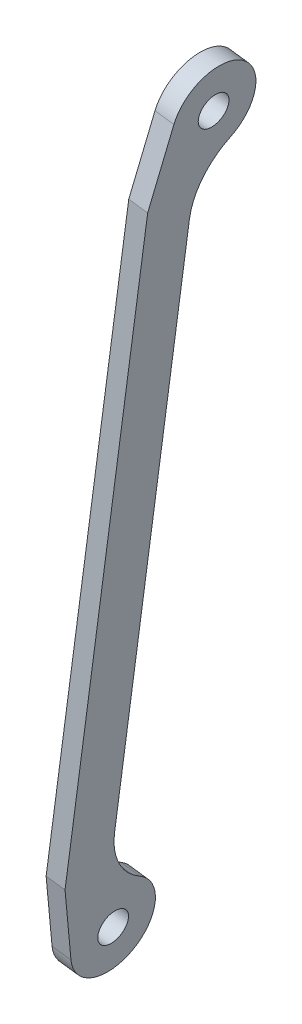
from build123d import *

# Parameters (mm, degrees)
SKETCH1_R             = 4
BOSS_EXTRUDE1_DEPTH   = 5
BODY_MOVE_COPY1_ANGLE = 82.5


with BuildPart() as part:
    # Sketch1 → Boss-Extrude1 (new body)
    with BuildSketch(Plane(origin=(0, 0, 0), x_dir=(1, 0, 0), z_dir=(0, 1, 0))):
        with BuildLine():
            Line((17.104515265, -14.844249905), (183.104515265, -14.844249905))
            Line((183.104515265, -14.844249905), (202.418839623, -10.490300594))
            ThreePointArc((202.418839623, -10.490300594), (208.912700196, 6.687224641), (190.565681892, 5.896960314))
            ThreePointArc((190.565681892, 5.896960314), (183.998945909, -0.509119996), (175.127942725, -2.846894344))
            Line((175.127942725, -2.846894344), (24.726164692, -2.84688969))
            ThreePointArc((24.726164692, -2.84688969), (15.931189962, -0.551933774), (9.378890583, 5.747730981))
            ThreePointArc((9.378890583, 5.747730981), (-8.988354121, 6.341095346), (-2.269343204, -10.763367569))
            Line((-2.269343204, -10.763367569), (17.104515265, -14.844249905))
        make_face()
        Circle(SKETCH1_R, mode=Mode.SUBTRACT)
        with Locations((199.999855487, 0.240427049)):
            Circle(SKETCH1_R, mode=Mode.SUBTRACT)
    extrude(amount=BOSS_EXTRUDE1_DEPTH)


with BuildPart() as part_1:
    # Body-Move/Copy1: moved
    add(part.part.rotate(Axis((99.999927744, 2.5, 0), (0, 0, 1)), BODY_MOVE_COPY1_ANGLE))


solid = part_1.part
